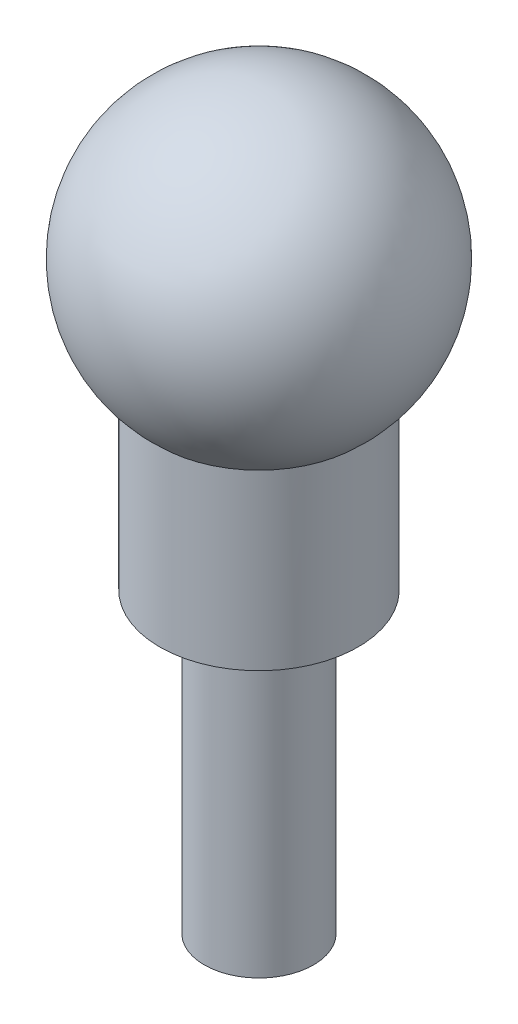
from build123d import *

# Parameters (mm, degrees)
SKETCH1_R           = 2.2
BOSS_EXTRUDE1_DEPTH = 12
SKETCH3_R           = 4
BOSS_EXTRUDE2_DEPTH = 7


with BuildPart() as part:
    # Sketch1 → Boss-Extrude1 (new body)
    with BuildSketch(Plane(origin=(0, 0, 0), x_dir=(1, 0, 0), z_dir=(0, 1, 0))):
        Circle(SKETCH1_R)
    extrude(amount=BOSS_EXTRUDE1_DEPTH)

    # Sketch3 → Boss-Extrude2 (add)
    with BuildSketch(Plane(origin=(0, 12, 0), x_dir=(1, 0, 0), z_dir=(0, 1, 0))):
        Circle(SKETCH3_R)
    extrude(amount=BOSS_EXTRUDE2_DEPTH)

    # Sketch4 → Revolve2 (revolve)
    with BuildSketch(Plane.XY):
        with BuildLine():
            Line((0, 28.11938617), (0, 19))
            Line((0, 19), (4, 19))
            ThreePointArc((4, 19), (5.676610407, 25.69672264), (0, 29.62523519))
            Line((0, 29.62523519), (0, 28.11938617))
        make_face()
    revolve(axis=Axis((0, 28.11938617, 0), (0, -1, 0)))


solid = part.part
